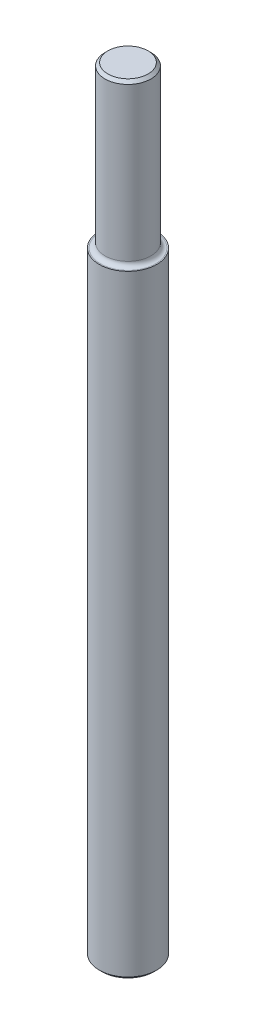
from build123d import *

# Parameters (mm, degrees)
SKETCH_1_R          = 10
EXTRUDE_1_DEPTH     = 270
SKETCH_2_OUTSIDE_W  = 76.296
SKETCH_2_OUTSIDE_H  = 76.296
SKETCH_2_OUTSIDE_R  = 8
CUT_EXTRUDE_2_DEPTH = 56
FILLET_1_R          = 1.6
CHAMFER_1_SIZE      = 1


with BuildPart() as part:
    # Эскиз1 → Вытянуть1 (new body)
    with BuildSketch(Plane(origin=(0, 0, 0), x_dir=(1, 0, 0), z_dir=(0, 1, 0))):
        Circle(SKETCH_1_R)
    extrude(amount=EXTRUDE_1_DEPTH)

    # Эскиз2 outside → Вытянуть2 (cut)
    with BuildSketch(Plane(origin=(0, 270, 0), x_dir=(1, 0, 0), z_dir=(0, 1, 0))):
        Rectangle(SKETCH_2_OUTSIDE_W, SKETCH_2_OUTSIDE_H)
        Circle(SKETCH_2_OUTSIDE_R, mode=Mode.SUBTRACT)
    extrude(amount=-CUT_EXTRUDE_2_DEPTH, mode=Mode.SUBTRACT)

    # Скругление1
    fillet_1_edges = [part.edges().sort_by_distance(p)[0] for p in [
        (-8, 214, 0),
    ]]
    fillet(fillet_1_edges, radius=FILLET_1_R)

    # Фаска1
    chamfer_1_edges = [part.edges().sort_by_distance(p)[0] for p in [
        (-8, 270, 0),
        (-10, 0, 0),
    ]]
    chamfer(chamfer_1_edges, length=CHAMFER_1_SIZE)


solid = part.part
